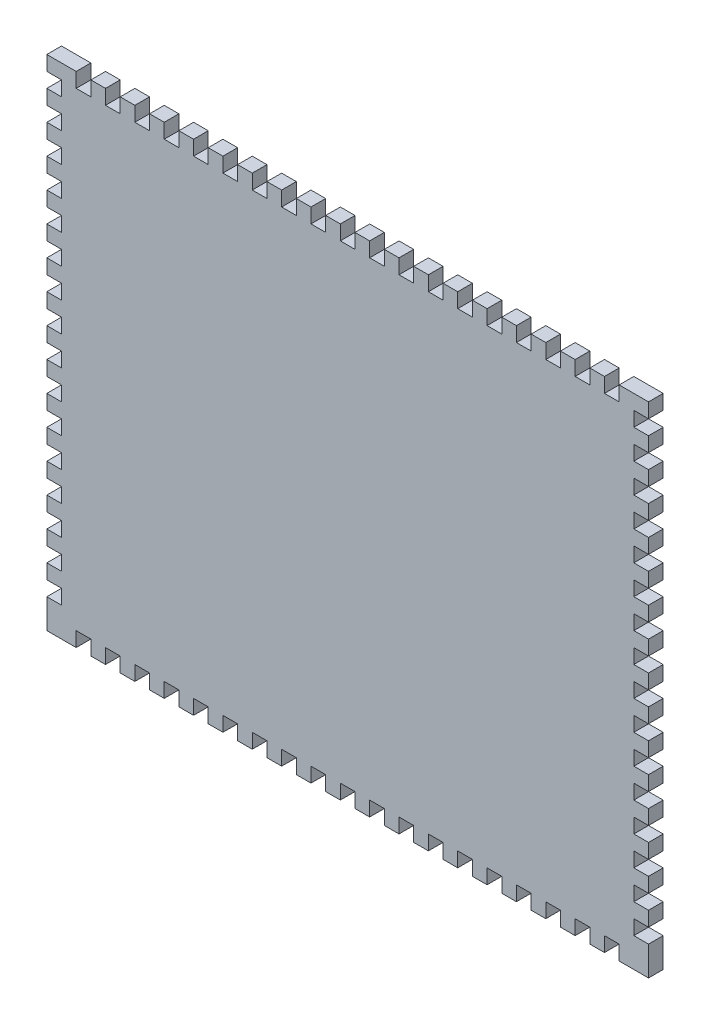
from build123d import *

# Parameters (mm, degrees)
SKETCH1_W                = 260.35
SKETCH1_H                = 215.9
BOSS_EXTRUDE1_DEPTH      = 6.35
SKETCH2_W                = 6.35
SKETCH2_H                = 6.35
CUT_EXTRUDE1_DEPTH       = 6.35
LPATTERN1_COUNT          = 16
LPATTERN1_PITCH          = 12.7
MIRROR1_COPY_1_SKETCH_W  = 6.35
MIRROR1_COPY_1_SKETCH_H  = 6.35
MIRROR1_COPY_1_DEPTH     = 6.35
MIRROR1_COPY_2_SKETCH_W  = 6.35
MIRROR1_COPY_2_SKETCH_H  = 6.35
MIRROR1_COPY_2_DEPTH     = 6.35
MIRROR1_COPY_3_SKETCH_W  = 6.35
MIRROR1_COPY_3_SKETCH_H  = 6.35
MIRROR1_COPY_3_DEPTH     = 6.35
MIRROR1_COPY_4_SKETCH_W  = 6.35
MIRROR1_COPY_4_SKETCH_H  = 6.35
MIRROR1_COPY_4_DEPTH     = 6.35
MIRROR1_COPY_5_SKETCH_W  = 6.35
MIRROR1_COPY_5_SKETCH_H  = 6.35
MIRROR1_COPY_5_DEPTH     = 6.35
MIRROR1_COPY_6_SKETCH_W  = 6.35
MIRROR1_COPY_6_SKETCH_H  = 6.35
MIRROR1_COPY_6_DEPTH     = 6.35
MIRROR1_COPY_7_SKETCH_W  = 6.35
MIRROR1_COPY_7_SKETCH_H  = 6.35
MIRROR1_COPY_7_DEPTH     = 6.35
MIRROR1_COPY_8_SKETCH_W  = 6.35
MIRROR1_COPY_8_SKETCH_H  = 6.35
MIRROR1_COPY_8_DEPTH     = 6.35
MIRROR1_COPY_9_SKETCH_W  = 6.35
MIRROR1_COPY_9_SKETCH_H  = 6.35
MIRROR1_COPY_9_DEPTH     = 6.35
MIRROR1_COPY_10_SKETCH_W = 6.35
MIRROR1_COPY_10_SKETCH_H = 6.35
MIRROR1_COPY_10_DEPTH    = 6.35
MIRROR1_COPY_11_SKETCH_W = 6.35
MIRROR1_COPY_11_SKETCH_H = 6.35
MIRROR1_COPY_11_DEPTH    = 6.35
MIRROR1_COPY_12_SKETCH_W = 6.35
MIRROR1_COPY_12_SKETCH_H = 6.35
MIRROR1_COPY_12_DEPTH    = 6.35
MIRROR1_COPY_13_SKETCH_W = 6.35
MIRROR1_COPY_13_SKETCH_H = 6.35
MIRROR1_COPY_13_DEPTH    = 6.35
MIRROR1_COPY_14_SKETCH_W = 6.35
MIRROR1_COPY_14_SKETCH_H = 6.35
MIRROR1_COPY_14_DEPTH    = 6.35
MIRROR1_COPY_15_SKETCH_W = 6.35
MIRROR1_COPY_15_SKETCH_H = 6.35
MIRROR1_COPY_15_DEPTH    = 6.35
CUT_EXTRUDE2_START       = -7.35
SKETCH3_W                = 6.35
SKETCH3_H                = 6.35
CUT_EXTRUDE2_DEPTH       = 8.35
LPATTERN2_COUNT          = 19
LPATTERN2_PITCH          = 12.7
MIRROR2_START            = -7.35
MIRROR2_COPY_1_SKETCH_W  = 6.35
MIRROR2_COPY_1_SKETCH_H  = 6.35
MIRROR2_COPY_1_DEPTH     = 8.35
MIRROR2_COPY_2_SKETCH_W  = 6.35
MIRROR2_COPY_2_SKETCH_H  = 6.35
MIRROR2_COPY_2_DEPTH     = 8.35
MIRROR2_COPY_3_SKETCH_W  = 6.35
MIRROR2_COPY_3_SKETCH_H  = 6.35
MIRROR2_COPY_3_DEPTH     = 8.35
MIRROR2_COPY_4_SKETCH_W  = 6.35
MIRROR2_COPY_4_SKETCH_H  = 6.35
MIRROR2_COPY_4_DEPTH     = 8.35
MIRROR2_COPY_5_SKETCH_W  = 6.35
MIRROR2_COPY_5_SKETCH_H  = 6.35
MIRROR2_COPY_5_DEPTH     = 8.35
MIRROR2_COPY_6_SKETCH_W  = 6.35
MIRROR2_COPY_6_SKETCH_H  = 6.35
MIRROR2_COPY_6_DEPTH     = 8.35
MIRROR2_COPY_7_SKETCH_W  = 6.35
MIRROR2_COPY_7_SKETCH_H  = 6.35
MIRROR2_COPY_7_DEPTH     = 8.35
MIRROR2_COPY_8_SKETCH_W  = 6.35
MIRROR2_COPY_8_SKETCH_H  = 6.35
MIRROR2_COPY_8_DEPTH     = 8.35
MIRROR2_COPY_9_SKETCH_W  = 6.35
MIRROR2_COPY_9_SKETCH_H  = 6.35
MIRROR2_COPY_9_DEPTH     = 8.35
MIRROR2_COPY_10_SKETCH_W = 6.35
MIRROR2_COPY_10_SKETCH_H = 6.35
MIRROR2_COPY_10_DEPTH    = 8.35
MIRROR2_COPY_11_SKETCH_W = 6.35
MIRROR2_COPY_11_SKETCH_H = 6.35
MIRROR2_COPY_11_DEPTH    = 8.35
MIRROR2_COPY_12_SKETCH_W = 6.35
MIRROR2_COPY_12_SKETCH_H = 6.35
MIRROR2_COPY_12_DEPTH    = 8.35
MIRROR2_COPY_13_SKETCH_W = 6.35
MIRROR2_COPY_13_SKETCH_H = 6.35
MIRROR2_COPY_13_DEPTH    = 8.35
MIRROR2_COPY_14_SKETCH_W = 6.35
MIRROR2_COPY_14_SKETCH_H = 6.35
MIRROR2_COPY_14_DEPTH    = 8.35
MIRROR2_COPY_15_SKETCH_W = 6.35
MIRROR2_COPY_15_SKETCH_H = 6.35
MIRROR2_COPY_15_DEPTH    = 8.35
MIRROR2_COPY_16_SKETCH_W = 6.35
MIRROR2_COPY_16_SKETCH_H = 6.35
MIRROR2_COPY_16_DEPTH    = 8.35
MIRROR2_COPY_17_SKETCH_W = 6.35
MIRROR2_COPY_17_SKETCH_H = 6.35
MIRROR2_COPY_17_DEPTH    = 8.35
MIRROR2_COPY_18_SKETCH_W = 6.35
MIRROR2_COPY_18_SKETCH_H = 6.35
MIRROR2_COPY_18_DEPTH    = 8.35


with BuildPart() as part:
    # Sketch1 → Boss-Extrude1 (new body)
    with BuildSketch(Plane.XY):
        Rectangle(SKETCH1_W, SKETCH1_H)
    extrude(amount=BOSS_EXTRUDE1_DEPTH)

    # Sketch2 → Cut-Extrude1 (cut)
    with BuildSketch(Plane.XY.offset(6.35)):
        with Locations((-127, -92.075)):
            Rectangle(SKETCH2_W, SKETCH2_H)
    cut_extrude1 = extrude(amount=-CUT_EXTRUDE1_DEPTH, mode=Mode.SUBTRACT)

    # LPattern1: Cut-Extrude1 ×16
    with Locations(*[(0, i * LPATTERN1_PITCH, 0) for i in range(1, LPATTERN1_COUNT)]):
        add(cut_extrude1, mode=Mode.SUBTRACT)

    # Mirror1: Cut-Extrude1 across plane
    add(cut_extrude1.mirror(Plane(origin=(0, 0, 0), x_dir=(0, 0, 1), z_dir=(1, 0, 0))), mode=Mode.SUBTRACT)

    # Mirror1 copy 1 sketch → Mirror1 copy 1 (cut)
    with BuildSketch(Plane(origin=(0, 12.7, 6.35), x_dir=(-1, 0, 0), z_dir=(0, 0, 1))):
        with Locations((-127, 92.075)):
            Rectangle(MIRROR1_COPY_1_SKETCH_W, MIRROR1_COPY_1_SKETCH_H)
    extrude(amount=-MIRROR1_COPY_1_DEPTH, mode=Mode.SUBTRACT)

    # Mirror1 copy 2 sketch → Mirror1 copy 2 (cut)
    with BuildSketch(Plane(origin=(0, 25.4, 6.35), x_dir=(-1, 0, 0), z_dir=(0, 0, 1))):
        with Locations((-127, 92.075)):
            Rectangle(MIRROR1_COPY_2_SKETCH_W, MIRROR1_COPY_2_SKETCH_H)
    extrude(amount=-MIRROR1_COPY_2_DEPTH, mode=Mode.SUBTRACT)

    # Mirror1 copy 3 sketch → Mirror1 copy 3 (cut)
    with BuildSketch(Plane(origin=(0, 38.1, 6.35), x_dir=(-1, 0, 0), z_dir=(0, 0, 1))):
        with Locations((-127, 92.075)):
            Rectangle(MIRROR1_COPY_3_SKETCH_W, MIRROR1_COPY_3_SKETCH_H)
    extrude(amount=-MIRROR1_COPY_3_DEPTH, mode=Mode.SUBTRACT)

    # Mirror1 copy 4 sketch → Mirror1 copy 4 (cut)
    with BuildSketch(Plane(origin=(0, 50.8, 6.35), x_dir=(-1, 0, 0), z_dir=(0, 0, 1))):
        with Locations((-127, 92.075)):
            Rectangle(MIRROR1_COPY_4_SKETCH_W, MIRROR1_COPY_4_SKETCH_H)
    extrude(amount=-MIRROR1_COPY_4_DEPTH, mode=Mode.SUBTRACT)

    # Mirror1 copy 5 sketch → Mirror1 copy 5 (cut)
    with BuildSketch(Plane(origin=(0, 63.5, 6.35), x_dir=(-1, 0, 0), z_dir=(0, 0, 1))):
        with Locations((-127, 92.075)):
            Rectangle(MIRROR1_COPY_5_SKETCH_W, MIRROR1_COPY_5_SKETCH_H)
    extrude(amount=-MIRROR1_COPY_5_DEPTH, mode=Mode.SUBTRACT)

    # Mirror1 copy 6 sketch → Mirror1 copy 6 (cut)
    with BuildSketch(Plane(origin=(0, 76.2, 6.35), x_dir=(-1, 0, 0), z_dir=(0, 0, 1))):
        with Locations((-127, 92.075)):
            Rectangle(MIRROR1_COPY_6_SKETCH_W, MIRROR1_COPY_6_SKETCH_H)
    extrude(amount=-MIRROR1_COPY_6_DEPTH, mode=Mode.SUBTRACT)

    # Mirror1 copy 7 sketch → Mirror1 copy 7 (cut)
    with BuildSketch(Plane(origin=(0, 88.9, 6.35), x_dir=(-1, 0, 0), z_dir=(0, 0, 1))):
        with Locations((-127, 92.075)):
            Rectangle(MIRROR1_COPY_7_SKETCH_W, MIRROR1_COPY_7_SKETCH_H)
    extrude(amount=-MIRROR1_COPY_7_DEPTH, mode=Mode.SUBTRACT)

    # Mirror1 copy 8 sketch → Mirror1 copy 8 (cut)
    with BuildSketch(Plane(origin=(0, 101.6, 6.35), x_dir=(-1, 0, 0), z_dir=(0, 0, 1))):
        with Locations((-127, 92.075)):
            Rectangle(MIRROR1_COPY_8_SKETCH_W, MIRROR1_COPY_8_SKETCH_H)
    extrude(amount=-MIRROR1_COPY_8_DEPTH, mode=Mode.SUBTRACT)

    # Mirror1 copy 9 sketch → Mirror1 copy 9 (cut)
    with BuildSketch(Plane(origin=(0, 114.3, 6.35), x_dir=(-1, 0, 0), z_dir=(0, 0, 1))):
        with Locations((-127, 92.075)):
            Rectangle(MIRROR1_COPY_9_SKETCH_W, MIRROR1_COPY_9_SKETCH_H)
    extrude(amount=-MIRROR1_COPY_9_DEPTH, mode=Mode.SUBTRACT)

    # Mirror1 copy 10 sketch → Mirror1 copy 10 (cut)
    with BuildSketch(Plane(origin=(0, 127, 6.35), x_dir=(-1, 0, 0), z_dir=(0, 0, 1))):
        with Locations((-127, 92.075)):
            Rectangle(MIRROR1_COPY_10_SKETCH_W, MIRROR1_COPY_10_SKETCH_H)
    extrude(amount=-MIRROR1_COPY_10_DEPTH, mode=Mode.SUBTRACT)

    # Mirror1 copy 11 sketch → Mirror1 copy 11 (cut)
    with BuildSketch(Plane(origin=(0, 139.7, 6.35), x_dir=(-1, 0, 0), z_dir=(0, 0, 1))):
        with Locations((-127, 92.075)):
            Rectangle(MIRROR1_COPY_11_SKETCH_W, MIRROR1_COPY_11_SKETCH_H)
    extrude(amount=-MIRROR1_COPY_11_DEPTH, mode=Mode.SUBTRACT)

    # Mirror1 copy 12 sketch → Mirror1 copy 12 (cut)
    with BuildSketch(Plane(origin=(0, 152.4, 6.35), x_dir=(-1, 0, 0), z_dir=(0, 0, 1))):
        with Locations((-127, 92.075)):
            Rectangle(MIRROR1_COPY_12_SKETCH_W, MIRROR1_COPY_12_SKETCH_H)
    extrude(amount=-MIRROR1_COPY_12_DEPTH, mode=Mode.SUBTRACT)

    # Mirror1 copy 13 sketch → Mirror1 copy 13 (cut)
    with BuildSketch(Plane(origin=(0, 165.1, 6.35), x_dir=(-1, 0, 0), z_dir=(0, 0, 1))):
        with Locations((-127, 92.075)):
            Rectangle(MIRROR1_COPY_13_SKETCH_W, MIRROR1_COPY_13_SKETCH_H)
    extrude(amount=-MIRROR1_COPY_13_DEPTH, mode=Mode.SUBTRACT)

    # Mirror1 copy 14 sketch → Mirror1 copy 14 (cut)
    with BuildSketch(Plane(origin=(0, 177.8, 6.35), x_dir=(-1, 0, 0), z_dir=(0, 0, 1))):
        with Locations((-127, 92.075)):
            Rectangle(MIRROR1_COPY_14_SKETCH_W, MIRROR1_COPY_14_SKETCH_H)
    extrude(amount=-MIRROR1_COPY_14_DEPTH, mode=Mode.SUBTRACT)

    # Mirror1 copy 15 sketch → Mirror1 copy 15 (cut)
    with BuildSketch(Plane(origin=(0, 190.5, 6.35), x_dir=(-1, 0, 0), z_dir=(0, 0, 1))):
        with Locations((-127, 92.075)):
            Rectangle(MIRROR1_COPY_15_SKETCH_W, MIRROR1_COPY_15_SKETCH_H)
    extrude(amount=-MIRROR1_COPY_15_DEPTH, mode=Mode.SUBTRACT)

    # Sketch3 → Cut-Extrude2 (cut)
    with BuildSketch(Plane.XY.offset(6.35).offset(CUT_EXTRUDE2_START)):
        with Locations((-114.3, 104.775)):
            Rectangle(SKETCH3_W, SKETCH3_H)
    cut_extrude2 = extrude(amount=CUT_EXTRUDE2_DEPTH, mode=Mode.SUBTRACT)

    # LPattern2: Cut-Extrude2 ×19
    with Locations(*[(i * LPATTERN2_PITCH, 0, 0) for i in range(1, LPATTERN2_COUNT)]):
        add(cut_extrude2, mode=Mode.SUBTRACT)

    # Mirror2: Cut-Extrude2 across plane
    add(cut_extrude2.mirror(Plane.ZX), mode=Mode.SUBTRACT)

    # Mirror2 copy 1 sketch → Mirror2 copy 1 (cut)
    with BuildSketch(Plane(origin=(12.7, 0, 6.35), x_dir=(1, 0, 0), z_dir=(0, 0, 1)).offset(MIRROR2_START)):
        with Locations((-114.3, -104.775)):
            Rectangle(MIRROR2_COPY_1_SKETCH_W, MIRROR2_COPY_1_SKETCH_H)
    extrude(amount=MIRROR2_COPY_1_DEPTH, mode=Mode.SUBTRACT)

    # Mirror2 copy 2 sketch → Mirror2 copy 2 (cut)
    with BuildSketch(Plane(origin=(25.4, 0, 6.35), x_dir=(1, 0, 0), z_dir=(0, 0, 1)).offset(MIRROR2_START)):
        with Locations((-114.3, -104.775)):
            Rectangle(MIRROR2_COPY_2_SKETCH_W, MIRROR2_COPY_2_SKETCH_H)
    extrude(amount=MIRROR2_COPY_2_DEPTH, mode=Mode.SUBTRACT)

    # Mirror2 copy 3 sketch → Mirror2 copy 3 (cut)
    with BuildSketch(Plane(origin=(38.1, 0, 6.35), x_dir=(1, 0, 0), z_dir=(0, 0, 1)).offset(MIRROR2_START)):
        with Locations((-114.3, -104.775)):
            Rectangle(MIRROR2_COPY_3_SKETCH_W, MIRROR2_COPY_3_SKETCH_H)
    extrude(amount=MIRROR2_COPY_3_DEPTH, mode=Mode.SUBTRACT)

    # Mirror2 copy 4 sketch → Mirror2 copy 4 (cut)
    with BuildSketch(Plane(origin=(50.8, 0, 6.35), x_dir=(1, 0, 0), z_dir=(0, 0, 1)).offset(MIRROR2_START)):
        with Locations((-114.3, -104.775)):
            Rectangle(MIRROR2_COPY_4_SKETCH_W, MIRROR2_COPY_4_SKETCH_H)
    extrude(amount=MIRROR2_COPY_4_DEPTH, mode=Mode.SUBTRACT)

    # Mirror2 copy 5 sketch → Mirror2 copy 5 (cut)
    with BuildSketch(Plane(origin=(63.5, 0, 6.35), x_dir=(1, 0, 0), z_dir=(0, 0, 1)).offset(MIRROR2_START)):
        with Locations((-114.3, -104.775)):
            Rectangle(MIRROR2_COPY_5_SKETCH_W, MIRROR2_COPY_5_SKETCH_H)
    extrude(amount=MIRROR2_COPY_5_DEPTH, mode=Mode.SUBTRACT)

    # Mirror2 copy 6 sketch → Mirror2 copy 6 (cut)
    with BuildSketch(Plane(origin=(76.2, 0, 6.35), x_dir=(1, 0, 0), z_dir=(0, 0, 1)).offset(MIRROR2_START)):
        with Locations((-114.3, -104.775)):
            Rectangle(MIRROR2_COPY_6_SKETCH_W, MIRROR2_COPY_6_SKETCH_H)
    extrude(amount=MIRROR2_COPY_6_DEPTH, mode=Mode.SUBTRACT)

    # Mirror2 copy 7 sketch → Mirror2 copy 7 (cut)
    with BuildSketch(Plane(origin=(88.9, 0, 6.35), x_dir=(1, 0, 0), z_dir=(0, 0, 1)).offset(MIRROR2_START)):
        with Locations((-114.3, -104.775)):
            Rectangle(MIRROR2_COPY_7_SKETCH_W, MIRROR2_COPY_7_SKETCH_H)
    extrude(amount=MIRROR2_COPY_7_DEPTH, mode=Mode.SUBTRACT)

    # Mirror2 copy 8 sketch → Mirror2 copy 8 (cut)
    with BuildSketch(Plane(origin=(101.6, 0, 6.35), x_dir=(1, 0, 0), z_dir=(0, 0, 1)).offset(MIRROR2_START)):
        with Locations((-114.3, -104.775)):
            Rectangle(MIRROR2_COPY_8_SKETCH_W, MIRROR2_COPY_8_SKETCH_H)
    extrude(amount=MIRROR2_COPY_8_DEPTH, mode=Mode.SUBTRACT)

    # Mirror2 copy 9 sketch → Mirror2 copy 9 (cut)
    with BuildSketch(Plane(origin=(114.3, 0, 6.35), x_dir=(1, 0, 0), z_dir=(0, 0, 1)).offset(MIRROR2_START)):
        with Locations((-114.3, -104.775)):
            Rectangle(MIRROR2_COPY_9_SKETCH_W, MIRROR2_COPY_9_SKETCH_H)
    extrude(amount=MIRROR2_COPY_9_DEPTH, mode=Mode.SUBTRACT)

    # Mirror2 copy 10 sketch → Mirror2 copy 10 (cut)
    with BuildSketch(Plane(origin=(127, 0, 6.35), x_dir=(1, 0, 0), z_dir=(0, 0, 1)).offset(MIRROR2_START)):
        with Locations((-114.3, -104.775)):
            Rectangle(MIRROR2_COPY_10_SKETCH_W, MIRROR2_COPY_10_SKETCH_H)
    extrude(amount=MIRROR2_COPY_10_DEPTH, mode=Mode.SUBTRACT)

    # Mirror2 copy 11 sketch → Mirror2 copy 11 (cut)
    with BuildSketch(Plane(origin=(139.7, 0, 6.35), x_dir=(1, 0, 0), z_dir=(0, 0, 1)).offset(MIRROR2_START)):
        with Locations((-114.3, -104.775)):
            Rectangle(MIRROR2_COPY_11_SKETCH_W, MIRROR2_COPY_11_SKETCH_H)
    extrude(amount=MIRROR2_COPY_11_DEPTH, mode=Mode.SUBTRACT)

    # Mirror2 copy 12 sketch → Mirror2 copy 12 (cut)
    with BuildSketch(Plane(origin=(152.4, 0, 6.35), x_dir=(1, 0, 0), z_dir=(0, 0, 1)).offset(MIRROR2_START)):
        with Locations((-114.3, -104.775)):
            Rectangle(MIRROR2_COPY_12_SKETCH_W, MIRROR2_COPY_12_SKETCH_H)
    extrude(amount=MIRROR2_COPY_12_DEPTH, mode=Mode.SUBTRACT)

    # Mirror2 copy 13 sketch → Mirror2 copy 13 (cut)
    with BuildSketch(Plane(origin=(165.1, 0, 6.35), x_dir=(1, 0, 0), z_dir=(0, 0, 1)).offset(MIRROR2_START)):
        with Locations((-114.3, -104.775)):
            Rectangle(MIRROR2_COPY_13_SKETCH_W, MIRROR2_COPY_13_SKETCH_H)
    extrude(amount=MIRROR2_COPY_13_DEPTH, mode=Mode.SUBTRACT)

    # Mirror2 copy 14 sketch → Mirror2 copy 14 (cut)
    with BuildSketch(Plane(origin=(177.8, 0, 6.35), x_dir=(1, 0, 0), z_dir=(0, 0, 1)).offset(MIRROR2_START)):
        with Locations((-114.3, -104.775)):
            Rectangle(MIRROR2_COPY_14_SKETCH_W, MIRROR2_COPY_14_SKETCH_H)
    extrude(amount=MIRROR2_COPY_14_DEPTH, mode=Mode.SUBTRACT)

    # Mirror2 copy 15 sketch → Mirror2 copy 15 (cut)
    with BuildSketch(Plane(origin=(190.5, 0, 6.35), x_dir=(1, 0, 0), z_dir=(0, 0, 1)).offset(MIRROR2_START)):
        with Locations((-114.3, -104.775)):
            Rectangle(MIRROR2_COPY_15_SKETCH_W, MIRROR2_COPY_15_SKETCH_H)
    extrude(amount=MIRROR2_COPY_15_DEPTH, mode=Mode.SUBTRACT)

    # Mirror2 copy 16 sketch → Mirror2 copy 16 (cut)
    with BuildSketch(Plane(origin=(203.2, 0, 6.35), x_dir=(1, 0, 0), z_dir=(0, 0, 1)).offset(MIRROR2_START)):
        with Locations((-114.3, -104.775)):
            Rectangle(MIRROR2_COPY_16_SKETCH_W, MIRROR2_COPY_16_SKETCH_H)
    extrude(amount=MIRROR2_COPY_16_DEPTH, mode=Mode.SUBTRACT)

    # Mirror2 copy 17 sketch → Mirror2 copy 17 (cut)
    with BuildSketch(Plane(origin=(215.9, 0, 6.35), x_dir=(1, 0, 0), z_dir=(0, 0, 1)).offset(MIRROR2_START)):
        with Locations((-114.3, -104.775)):
            Rectangle(MIRROR2_COPY_17_SKETCH_W, MIRROR2_COPY_17_SKETCH_H)
    extrude(amount=MIRROR2_COPY_17_DEPTH, mode=Mode.SUBTRACT)

    # Mirror2 copy 18 sketch → Mirror2 copy 18 (cut)
    with BuildSketch(Plane(origin=(228.6, 0, 6.35), x_dir=(1, 0, 0), z_dir=(0, 0, 1)).offset(MIRROR2_START)):
        with Locations((-114.3, -104.775)):
            Rectangle(MIRROR2_COPY_18_SKETCH_W, MIRROR2_COPY_18_SKETCH_H)
    extrude(amount=MIRROR2_COPY_18_DEPTH, mode=Mode.SUBTRACT)


solid = part.part
